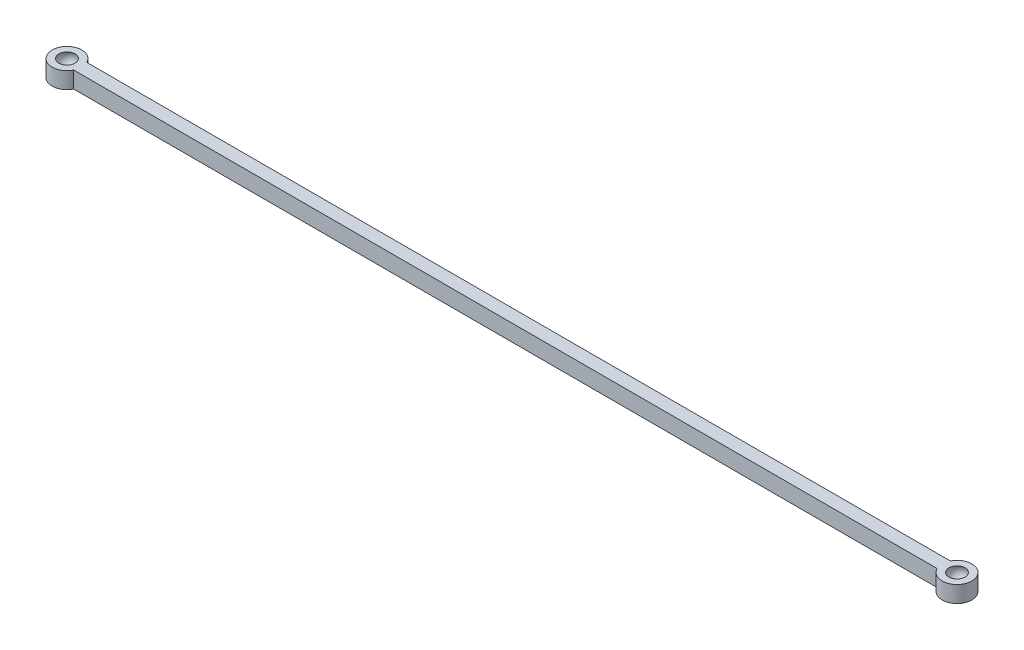
from build123d import *

# Parameters (mm, degrees)
BOSS_EXTRUDE1_DEPTH = 5


with BuildPart() as part:
    # Sketch1 → Boss-Extrude1 (new body)
    with BuildSketch(Plane(origin=(0, 0, 0), x_dir=(1, 0, 0), z_dir=(0, 1, 0))):
        with BuildLine():
            Line((-135, 2), (-135, -2))
            Line((-135, -2), (-130.968871126, -2))
            ThreePointArc((-130.968871126, -2), (-130.61878556, -1.027112473), (-130.5, 0))
            ThreePointArc((-130.5, 0), (-130.61878556, 1.027112473), (-130.968871126, 2))
            Line((-130.968871126, 2), (-135, 2))
        make_face()
        with BuildLine():
            Line((-130.968871126, -2), (-135, -2))
            Line((-135, -2), (-135, 2))
            Line((-135, 2), (-130.968871126, 2))
            ThreePointArc((-130.968871126, 2), (-139.5, 0), (-130.968871126, -2))
        make_face()
        with BuildLine():
            ThreePointArc((-130.5, 0), (-130.61878556, -1.027112473), (-130.968871126, -2))
            Line((-130.968871126, -2), (130.968871126, -2))
            ThreePointArc((130.968871126, -2), (130.5, 0), (130.968871126, 2))
            Line((130.968871126, 2), (-130.968871126, 2))
            ThreePointArc((-130.968871126, 2), (-130.61878556, 1.027112473), (-130.5, 0))
        make_face()
        with BuildLine():
            ThreePointArc((130.968871126, 2), (130.5, 0), (130.968871126, -2))
            Line((130.968871126, -2), (135, -2))
            Line((135, -2), (135, 2))
            Line((135, 2), (130.968871126, 2))
        make_face()
        with BuildLine():
            Line((135, -2), (130.968871126, -2))
            ThreePointArc((130.968871126, -2), (136.027112473, -4.38121444), (139.5, 0))
            ThreePointArc((139.5, 0), (136.027112473, 4.38121444), (130.968871126, 2))
            Line((130.968871126, 2), (135, 2))
            Line((135, 2), (135, -2))
        make_face()
    extrude(amount=BOSS_EXTRUDE1_DEPTH)

    # Cut-Sweep1: sweep along a path in Sketch2
    with BuildLine(Plane(origin=(0, 5, 0), x_dir=(1, 0, 0), z_dir=(0, 1, 0))) as cut_sweep1_path:
        CenterArc((-135, 0), 4.5, 0, 360)
    # 3DSketch1 → Cut-Sweep1 (sweep, cut)
    with BuildSketch(Plane(origin=(-135, 5, 0), x_dir=(0, -1, 0), z_dir=(-1, 0, 0))):
        with BuildLine():
            Line((0, 0), (-1.5, 0))
            ThreePointArc((-1.5, 0), (1.25, -2.75), (4, 0))
            Line((4, 0), (0, 0))
        make_face()
    cut_sweep1 = sweep(path=cut_sweep1_path.line, mode=Mode.SUBTRACT)

    # Mirror1: Cut-Sweep1 across plane
    add(cut_sweep1.mirror(Plane(origin=(0, 0, 0), x_dir=(0, 0, 1), z_dir=(1, 0, 0))), mode=Mode.SUBTRACT)


solid = part.part
